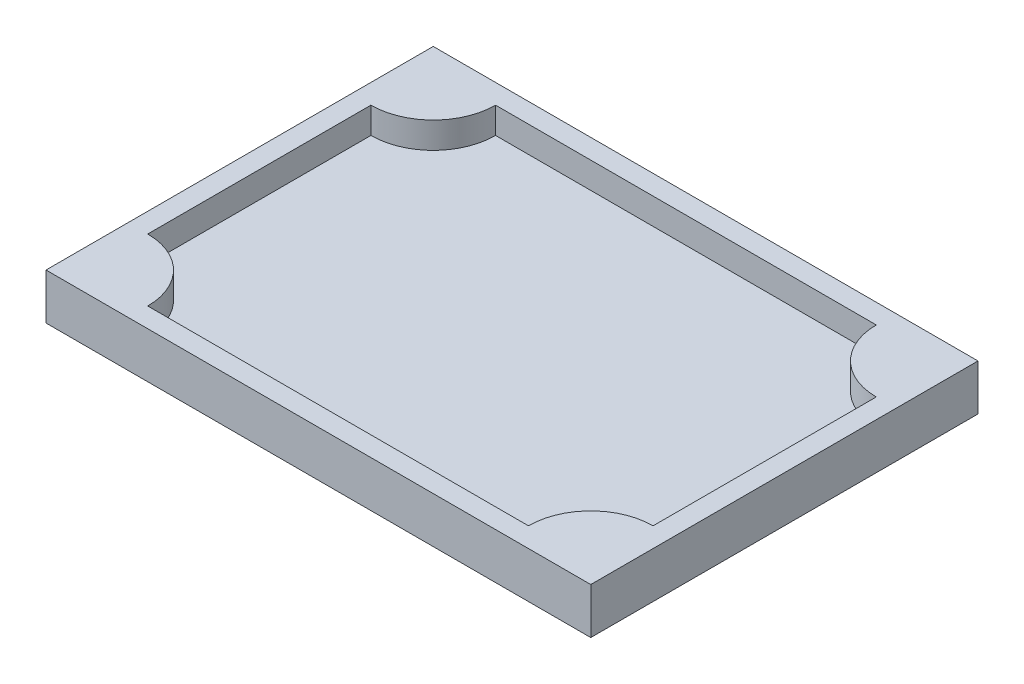
from build123d import *

# Parameters (mm, degrees)
SKETCH1_W           = 83
SKETCH1_H           = 59
BOSS_EXTRUDE1_DEPTH = 3
SKETCH2_W           = 83
SKETCH2_H           = 59
BOSS_EXTRUDE2_DEPTH = 4


with BuildPart() as part:
    # Sketch1 → Boss-Extrude1 (new body)
    with BuildSketch(Plane(origin=(0, 0, 0), x_dir=(1, 0, 0), z_dir=(0, 1, 0))):
        with Locations((41.5, 29.5)):
            Rectangle(SKETCH1_W, SKETCH1_H)
    extrude(amount=BOSS_EXTRUDE1_DEPTH)

    # Sketch2 → Boss-Extrude2 (add)
    with BuildSketch(Plane(origin=(0, 3, 0), x_dir=(1, 0, 0), z_dir=(0, 1, 0))):
        with Locations((41.5, 29.5)):
            Rectangle(SKETCH2_W, SKETCH2_H)
        with BuildLine():
            Line((3, 46.5), (3, 12.5))
            ThreePointArc((3, 12.5), (9.717514421, 9.717514421), (12.5, 3))
            Line((12.5, 3), (70.5, 3))
            ThreePointArc((70.5, 3), (73.282485579, 9.717514421), (80, 12.5))
            Line((80, 12.5), (80, 46.5))
            ThreePointArc((80, 46.5), (73.282485579, 49.282485579), (70.5, 56))
            Line((70.5, 56), (12.5, 56))
            ThreePointArc((12.5, 56), (9.717514421, 49.282485579), (3, 46.5))
        make_face(mode=Mode.SUBTRACT)
    extrude(amount=BOSS_EXTRUDE2_DEPTH)


solid = part.part
